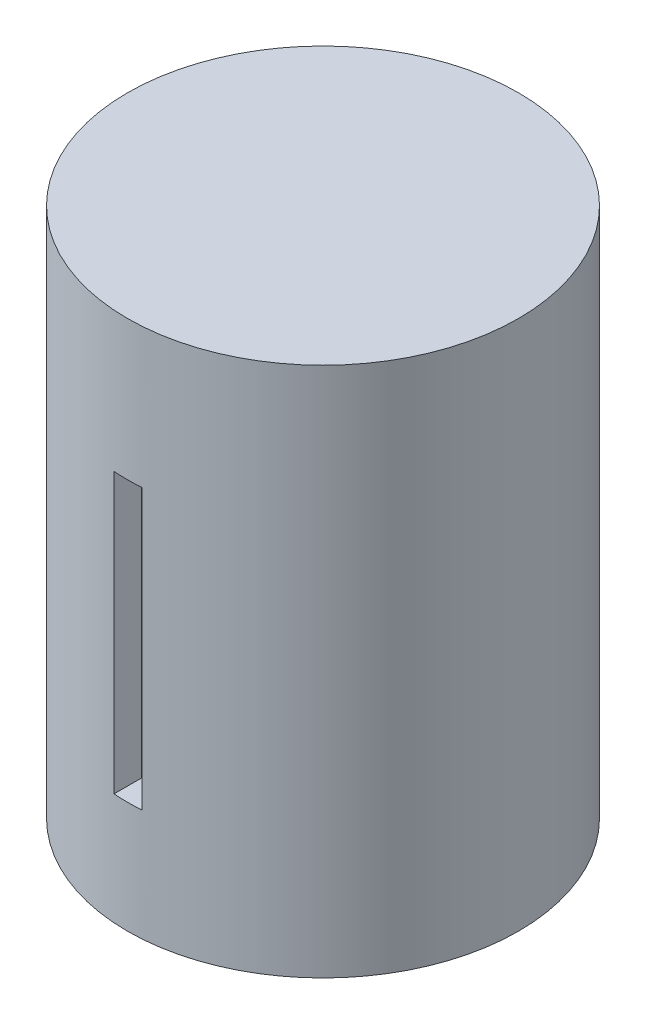
from build123d import *

# Parameters (mm, degrees)
SKETCH1_R           = 14
BOSS_EXTRUDE1_DEPTH = 38
CUT_EXTRUDE1_START  = 8
SKETCH2_W           = 2
SKETCH2_H           = 3
CUT_EXTRUDE1_DEPTH  = 20


with BuildPart() as part:
    # Sketch1 → Boss-Extrude1 (new body)
    with BuildSketch(Plane(origin=(0, 0, 0), x_dir=(1, 0, 0), z_dir=(0, 1, 0))):
        Circle(SKETCH1_R)
    extrude(amount=BOSS_EXTRUDE1_DEPTH)

    # Sketch2 → Cut-Extrude1 (cut)
    with BuildSketch(Plane(origin=(0, 0, 0), x_dir=(1, 0, 0), z_dir=(0, 1, 0)).offset(CUT_EXTRUDE1_START)):
        with Locations((0, -13.5)):
            Rectangle(SKETCH2_W, SKETCH2_H)
    extrude(amount=CUT_EXTRUDE1_DEPTH, mode=Mode.SUBTRACT)


solid = part.part
